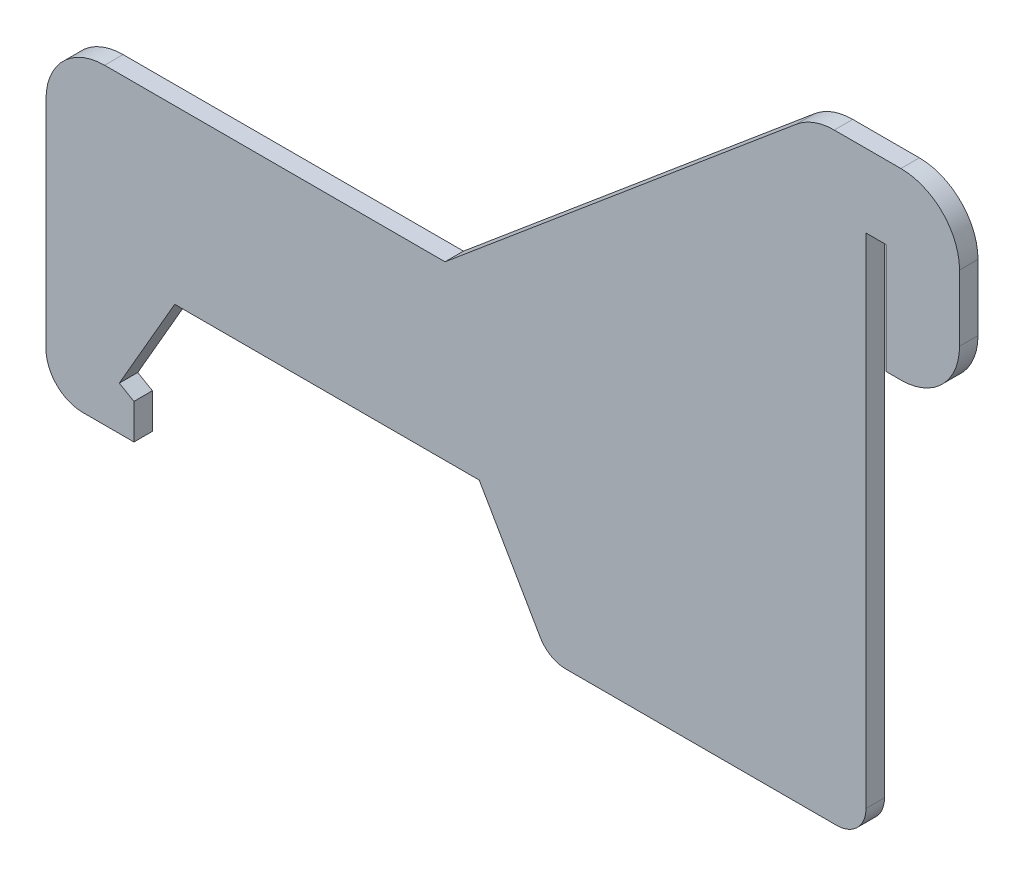
from build123d import *

# Parameters (mm, degrees)
BOSS_EXTRUDE1_DEPTH = 0.8001


with BuildPart() as part:
    # Sketch1 → Boss-Extrude1 (new body, symmetric)
    with BuildSketch(Plane.XY):
        with BuildLine():
            Line((27.250759249, 1.2954), (21.965453493, 10.449818102))
            Line((21.965453493, 10.449818102), (-4.418491784, 10.449818102))
            Line((-4.418491784, 10.449818102), (-9.22042678, 2.132622715))
            Line((-9.22042678, 2.132622715), (-7.95042678, 1.399387873))
            Line((-7.95042678, 1.399387873), (-7.95042678, -1.651))
            Line((-7.95042678, -1.651), (-12.39542678, -1.651))
            ThreePointArc((-12.39542678, -1.651), (-14.64049081, -0.72106403), (-15.57042678, 1.524))
            Line((-15.57042678, 1.524), (-15.57042678, 20.2692))
            ThreePointArc((-15.57042678, 20.2692), (-14.082529228, 23.861302448), (-10.49042678, 25.3492))
            Line((-10.49042678, 25.3492), (19.001320062, 25.3492))
            Line((19.001320062, 25.3492), (49.459807733, 50.906905771))
            ThreePointArc((49.459807733, 50.906905771), (50.987706462, 51.789038514), (52.72516879, 52.0954))
            Line((52.72516879, 52.0954), (58.4962, 52.0954))
            ThreePointArc((58.4962, 52.0954), (62.088302448, 50.607502448), (63.5762, 47.0154))
            Line((63.5762, 47.0154), (63.5762, 41.3004))
            ThreePointArc((63.5762, 41.3004), (62.088302448, 37.708297552), (58.4962, 36.2204))
            Line((58.4962, 36.2204), (57.2262, 36.2204))
            Line((57.2262, 36.2204), (57.2262, 45.7454))
            Line((57.2262, 45.7454), (55.4736, 45.7454))
            Line((55.4736, 45.7454), (55.4736, 2.5654))
            ThreePointArc((55.4736, 2.5654), (54.729651224, 0.769348776), (52.9336, 0.0254))
            Line((52.9336, 0.0254), (29.450463774, 0.0254))
            ThreePointArc((29.450463774, 0.0254), (28.180463774, 0.365695474), (27.250759249, 1.2954))
        make_face()
    extrude(amount=BOSS_EXTRUDE1_DEPTH, both=True)


solid = part.part
